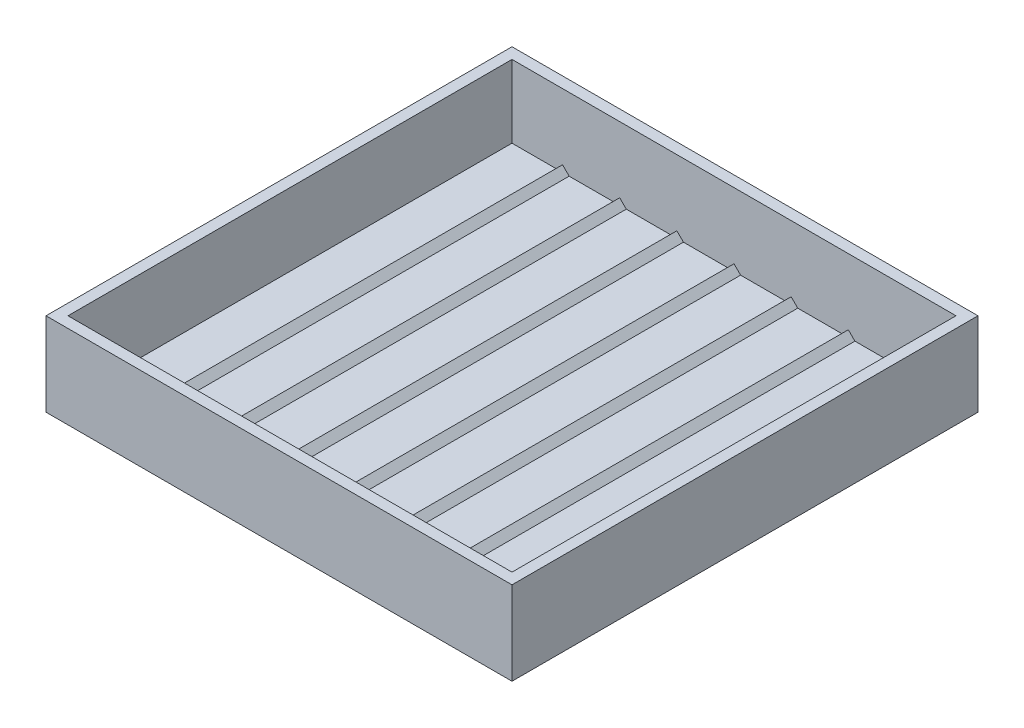
from build123d import *

# Parameters (mm, degrees)
SKETCH1_W           = 106
SKETCH1_H           = 19
BOSS_EXTRUDE1_DEPTH = 2.5
BOSS_EXTRUDE2_DEPTH = 50.5


with BuildPart() as part:
    # Sketch1 → Boss-Extrude1 (new body)
    with BuildSketch(Plane.XY):
        Rectangle(SKETCH1_W, SKETCH1_H)
    extrude(amount=-BOSS_EXTRUDE1_DEPTH)

    # Sketch1_3 → Boss-Extrude2 (add)
    with BuildSketch(Plane.XY):
        Polygon((-40.5, -7), (-50.5, -7), (-50.5, 9.5), (-53, 9.5), (-53, -9.5), (53, -9.5), (53, 9.5), (50.5, 9.5), (50.5, -7), (40.5, -7), (39, -5.5), (37.5, -7), (27.5, -7), (26, -5.5), (24.5, -7), (14.5, -7), (13, -5.5), (11.5, -7), (1.5, -7), (0, -5.5), (-1.5, -7), (-11.5, -7), (-13, -5.5), (-14.5, -7), (-24.5, -7), (-26, -5.5), (-27.5, -7), (-37.5, -7), (-39, -5.5), align=None)
    extrude(amount=BOSS_EXTRUDE2_DEPTH)

    # Mirror4: part across plane


with BuildPart() as part_1:
    add(part.part)
    add(part.part.mirror(Plane.XY.offset(50.5)))


solid = part_1.part
